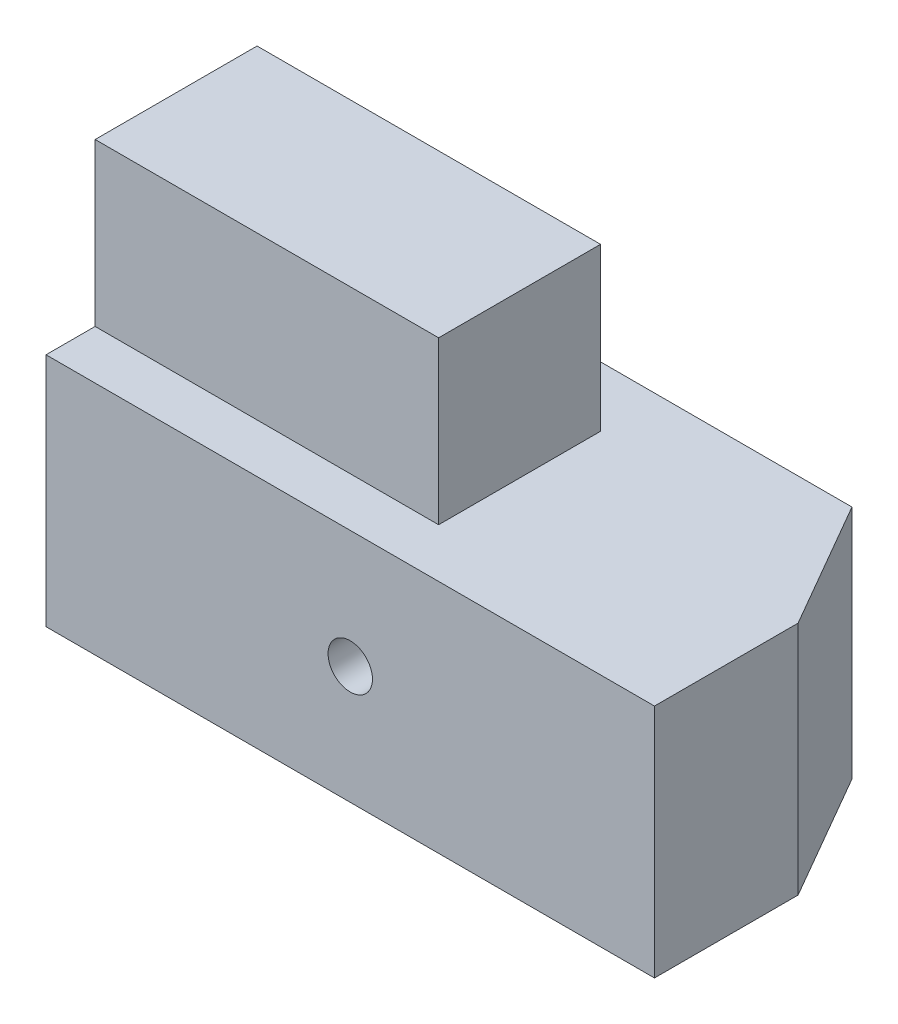
from build123d import *

# Parameters (mm, degrees)
SKETCH1_W           = 124
SKETCH1_H           = 48
SKETCH1_R           = 4.525
BOSS_EXTRUDE1_DEPTH = 55.25
SKETCH2_W           = 70
SKETCH2_H           = 33
BOSS_EXTRUDE2_DEPTH = 33
CHAMFER1_SIZE       = 15
CHAMFER1_SIZE2      = 25.980762114


with BuildPart() as part:
    # Sketch1 → Boss-Extrude1 (new body)
    with BuildSketch(Plane.XY):
        Rectangle(SKETCH1_W, SKETCH1_H)
        Circle(SKETCH1_R, mode=Mode.SUBTRACT)
    extrude(amount=-BOSS_EXTRUDE1_DEPTH)

    # Sketch2 → Boss-Extrude2 (add)
    with BuildSketch(Plane(origin=(0, 24, 0), x_dir=(1, 0, 0), z_dir=(0, 1, 0))):
        with Locations((-26.99, 26.5)):
            Rectangle(SKETCH2_W, SKETCH2_H)
    extrude(amount=BOSS_EXTRUDE2_DEPTH)

    # Chamfer1
    chamfer1_edges = [part.edges().sort_by_distance(p)[0] for p in [
        (62, 0, -55.25),
    ]]
    chamfer1_side = [part.faces().sort_by_distance(p)[0] for p in [
        (0, 22.670338389, -55.25),
    ]]
    chamfer(chamfer1_edges, length=CHAMFER1_SIZE, length2=CHAMFER1_SIZE2, reference=chamfer1_side[0])


solid = part.part
